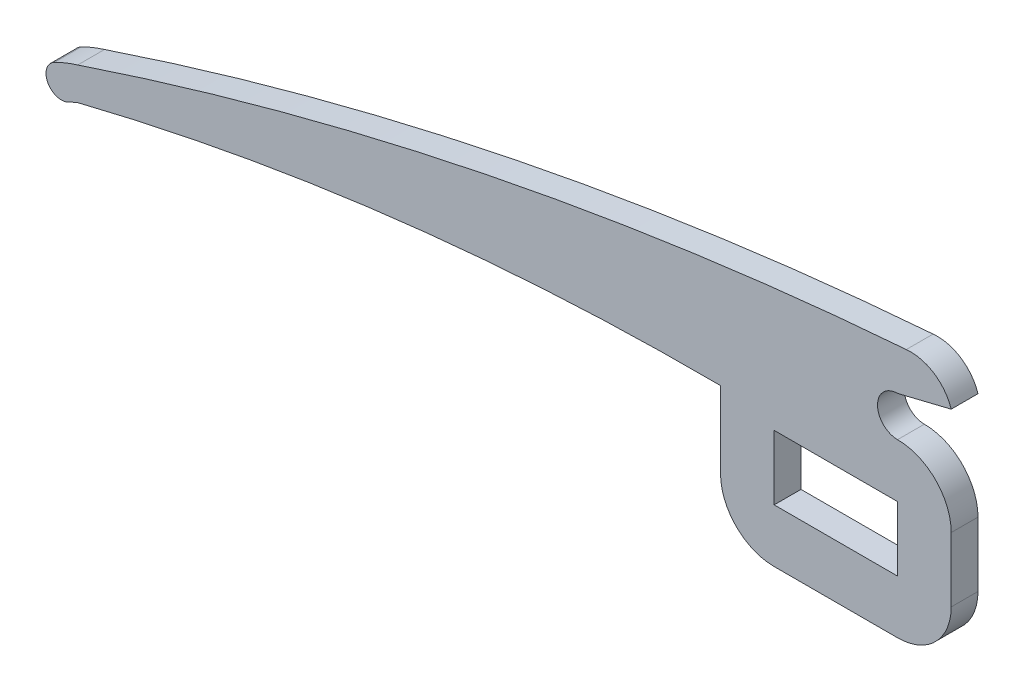
from build123d import *

# Parameters (mm, degrees)
SKETCH4_W           = 23.01079085
SKETCH4_H           = 12.035429775
BOSS_EXTRUDE1_DEPTH = 5


with BuildPart() as part:
    # Sketch4 → Boss-Extrude1 (new body)
    with BuildSketch(Plane.XY):
        with BuildLine():
            Line((-23.029498644, -9.969527596), (0.020059035, -9.969527596))
            ThreePointArc((0.020059035, -9.969527596), (7.083752781, -7.043649902), (10.009630666, 0.020043765))
            Line((10.009630666, 0.020043765), (10.009630666, 12.035429505))
            ThreePointArc((10.009630666, 12.035429505), (7.077737043, 19.110165135), (0.00232147, 22.0404175))
            ThreePointArc((0.00232147, 22.0404175), (-3.734235721, 25.776974691), (0.00232147, 29.513531883))
            Line((0.00232147, 29.513531883), (10.009630666, 31.965921786))
            ThreePointArc((10.009630666, 31.965921786), (6.784699168, 36.172527862), (1.631535857, 37.413747311))
            ThreePointArc((1.631535857, 37.413747311), (-76.612020645, 26.532654718), (-152.922807067, 6.10923224))
            ThreePointArc((-152.922807067, 6.10923224), (-155.131459045, 5.328115377), (-157.265351369, 4.361269649))
            ThreePointArc((-157.265351369, 4.361269649), (-158.533663589, 0.498259669), (-154.67065361, -0.770052551))
            ThreePointArc((-154.67065361, -0.770052551), (-153.805456008, -0.356328461), (-152.922807067, 0.018725346))
            ThreePointArc((-152.922807067, 0.018725346), (-93.417009782, 10.900895291), (-33.017751587, 14.261124841))
            Line((-33.017751587, 14.261124841), (-33.017751587, 12.035429775))
            Line((-33.017751587, 12.035429775), (-33.017751587, 0.018725346))
            ThreePointArc((-33.017751587, 0.018725346), (-30.092260032, -7.044036042), (-23.029498644, -9.969527596))
        make_face()
        with Locations((-11.505395425, 6.017714888)):
            Rectangle(SKETCH4_W, SKETCH4_H, mode=Mode.SUBTRACT)
    extrude(amount=BOSS_EXTRUDE1_DEPTH)


with BuildPart() as part_1:
    # Body-Move/Copy1: moved
    add(part.part.moved(Location((0, 0, -5))))


solid = part_1.part
